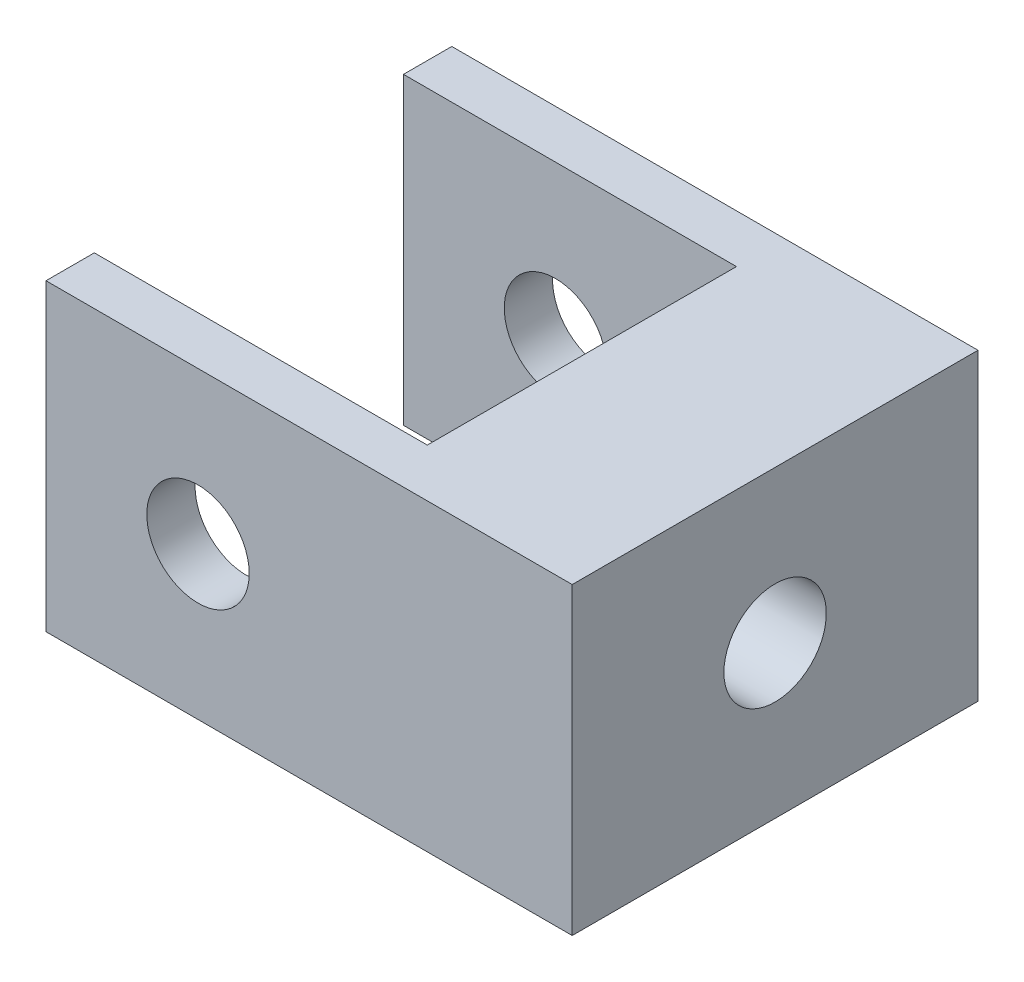
from build123d import *

# Parameters (mm, degrees)
BELT_TENSIONER_SKETCH_W        = 10
BELT_TENSIONER_SKETCH_H        = 15.732395448
BODY_EXTRUDE_DEPTH             = 10.5
CUT_EXTRUDE1_DEPTH             = 8
CBORE_FOR_M5_SHCS1_D           = 5.3
CBORE_FOR_M5_SHCS1_CBORE_D     = 10
CBORE_FOR_M5_SHCS1_CBORE_DEPTH = 5
M5_CLEARANCE_HOLE1_D           = 5.3


with BuildPart() as part:
    # Belt Tensioner Sketch → Body Extrude (new body, symmetric)
    with BuildSketch(Plane.XY):
        Polygon((-7.866197724, -7.866197724), (0, -7.866197724), (9.366197724, -7.866197724), (9.366197724, 7.866197724), (0, 7.866197724), (-7.866197724, 7.866197724), align=None)
        with Locations((14.366197724, 0)):
            Rectangle(BELT_TENSIONER_SKETCH_W, BELT_TENSIONER_SKETCH_H)
    extrude(amount=BODY_EXTRUDE_DEPTH, both=True)

    # Belt Tensioner Sketch_3 → Cut-Extrude1 (cut, symmetric)
    with BuildSketch(Plane.XY):
        Polygon((-7.866197724, -7.866197724), (0, -7.866197724), (9.366197724, -7.866197724), (9.366197724, 7.866197724), (0, 7.866197724), (-7.866197724, 7.866197724), align=None)
    extrude(amount=CUT_EXTRUDE1_DEPTH, both=True, mode=Mode.SUBTRACT)

    # CBORE for M5 SHCS1 (through all)
    with Locations(Plane.ZY.offset(-9.366197724)):
        with Locations((0, 0)):
            CounterBoreHole(CBORE_FOR_M5_SHCS1_D / 2, CBORE_FOR_M5_SHCS1_CBORE_D / 2, CBORE_FOR_M5_SHCS1_CBORE_DEPTH)

    # M5 Clearance Hole1 (through all)
    with Locations(Plane.XY.offset(10.5)):
        with Locations((0, 0)):
            Hole(M5_CLEARANCE_HOLE1_D / 2)


solid = part.part
